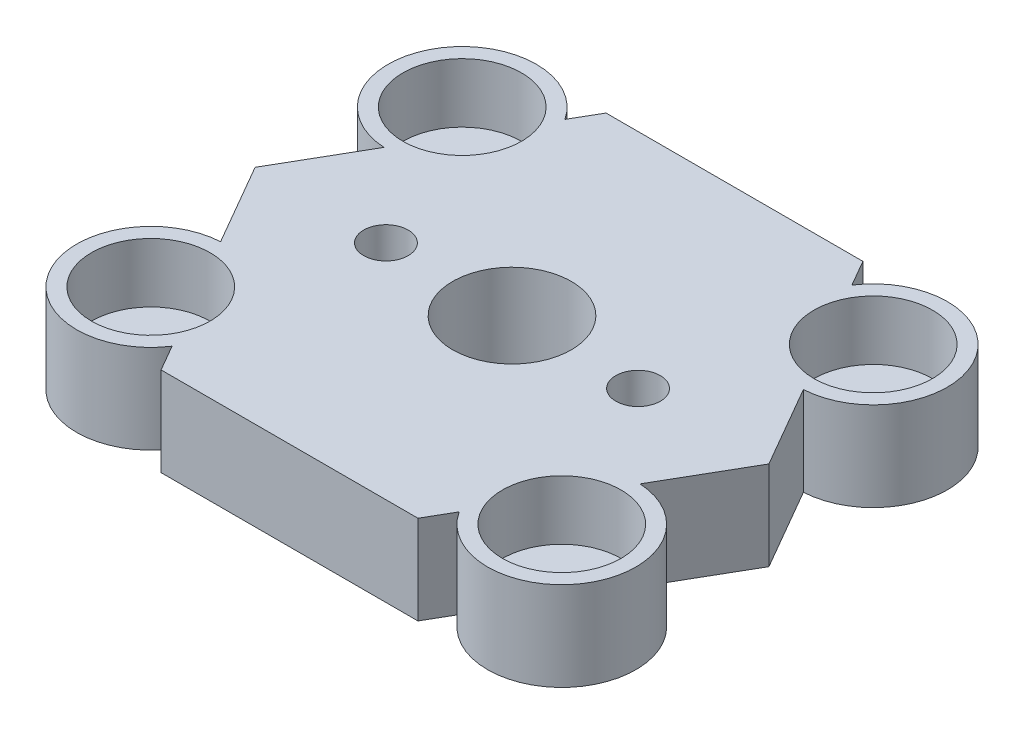
from build123d import *

# Parameters (mm, degrees)
SKETCH2_R           = 5
SKETCH2_R_2         = 1.5
SKETCH2_R_3         = 4
BOSS_EXTRUDE1_DEPTH = 6
SKETCH3_R           = 3.5
CUT_EXTRUDE3_DEPTH  = 3
SKETCH4_R           = 4
CUT_EXTRUDE4_DEPTH  = 4


with BuildPart() as part:
    # Sketch2 → Boss-Extrude1 (new body)
    with BuildSketch(Plane(origin=(0, 0, 0), x_dir=(1, 0, 0), z_dir=(0, 1, 0))):
        with Locations((-13.856406461, 10.5)):
            Circle(SKETCH2_R)
        with Locations((-13.856406461, 10.5)):
            Circle(SKETCH2_R_2, mode=Mode.SUBTRACT)
        with Locations((13.856406461, 10.5)):
            Circle(SKETCH2_R)
        with Locations((13.856406461, 10.5)):
            Circle(SKETCH2_R_2, mode=Mode.SUBTRACT)
        with Locations((13.856406461, -10.5)):
            Circle(SKETCH2_R)
        with Locations((13.856406461, -10.5)):
            Circle(SKETCH2_R_2, mode=Mode.SUBTRACT)
        with Locations((-13.856406461, -10.5)):
            Circle(SKETCH2_R)
        with Locations((-13.856406461, -10.5)):
            Circle(SKETCH2_R_2, mode=Mode.SUBTRACT)
        Polygon((17.320508076, 0), (8.660254038, 15), (-8.660254038, 15), (-17.320508076, 0), (-8.660254038, -15), (8.660254038, -15), align=None)
        Circle(SKETCH2_R_3, mode=Mode.SUBTRACT)
        with Locations((8.5, 0)):
            Circle(SKETCH2_R_2, mode=Mode.SUBTRACT)
        with Locations((-8.5, 0)):
            Circle(SKETCH2_R_2, mode=Mode.SUBTRACT)
    extrude(amount=BOSS_EXTRUDE1_DEPTH)

    # Sketch3 → Cut-Extrude3 (cut)
    with BuildSketch(Plane.XZ):
        with Locations((-8.5, 0)):
            Circle(SKETCH3_R)
        with Locations((8.5, 0)):
            Circle(SKETCH3_R)
    extrude(amount=-CUT_EXTRUDE3_DEPTH, mode=Mode.SUBTRACT)

    # Sketch4 → Cut-Extrude4 (cut)
    with BuildSketch(Plane(origin=(0, 6, 0), x_dir=(1, 0, 0), z_dir=(0, 1, 0))):
        with Locations((-13.856406461, 10.5)):
            Circle(SKETCH4_R)
        with Locations((13.856406461, 10.5)):
            Circle(SKETCH4_R)
        with Locations((-13.856406461, -10.5)):
            Circle(SKETCH4_R)
        with Locations((13.856406461, -10.5)):
            Circle(SKETCH4_R)
    extrude(amount=-CUT_EXTRUDE4_DEPTH, mode=Mode.SUBTRACT)


solid = part.part
